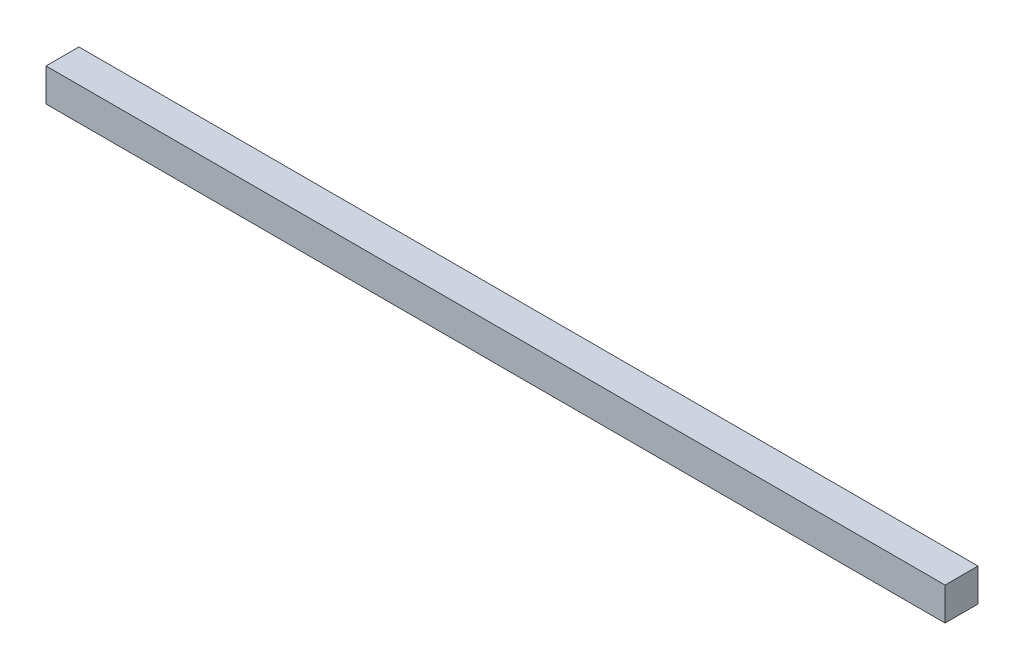
from build123d import *

# Parameters (mm, degrees)
ESQUISSE1_W        = 273
ESQUISSE1_H        = 10
BOSS_EXTRU_1_DEPTH = 10


with BuildPart() as part:
    # Esquisse1 → Boss.-Extru.1 (new body)
    with BuildSketch(Plane.XY):
        with Locations((-81.316611842, 69.791666667)):
            Rectangle(ESQUISSE1_W, ESQUISSE1_H)
    extrude(amount=BOSS_EXTRU_1_DEPTH)


solid = part.part
